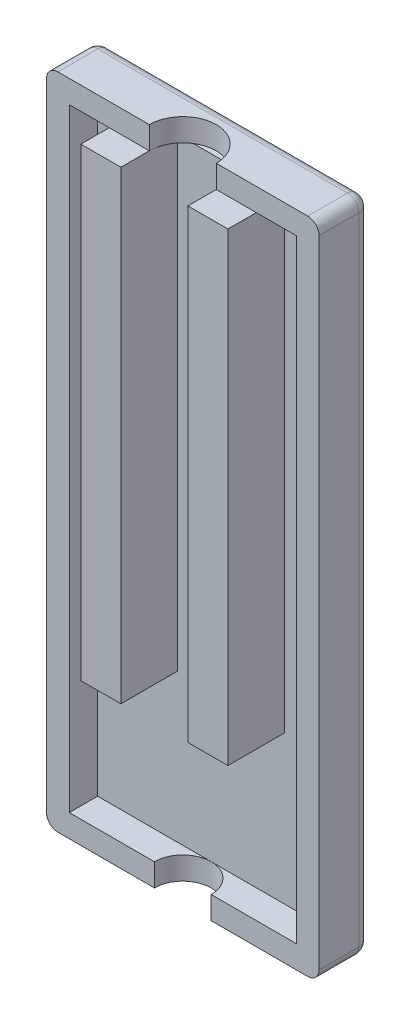
from build123d import *

# Parameters (mm, degrees)
SKETCH1_W           = 24
SKETCH1_H           = 58
BOSS_EXTRUDE1_DEPTH = 2
BOSS_EXTRUDE2_DEPTH = 2.5
CUT_EXTRUDE3_DEPTH  = 3
CUT_EXTRUDE4_DEPTH  = 3
SKETCH7_W           = 3.525
SKETCH7_H           = 40.926519782
BOSS_EXTRUDE3_DEPTH = 5
FILLET1_R           = 1


with BuildPart() as part:
    # Sketch1 → Boss-Extrude1 (new body)
    with BuildSketch(Plane.XY):
        with Locations((0, 4)):
            Rectangle(SKETCH1_W, SKETCH1_H)
    extrude(amount=BOSS_EXTRUDE1_DEPTH)

    # Sketch2 → Boss-Extrude2 (add)
    with BuildSketch(Plane.XY.offset(2)):
        Polygon((12, 33), (-12, 33), (-12, -25), (12, -25), (12, 9), align=None)
        Polygon((-10, -23), (-10, 23), (-10, 31), (10, 31), (10, 23), (10, -23), align=None, mode=Mode.SUBTRACT)
    extrude(amount=BOSS_EXTRUDE2_DEPTH)

    # Sketch5 → Cut-Extrude3 (cut, through all)
    with BuildSketch(Plane.XZ.offset(-31)):
        with BuildLine():
            Line((-2.95, 4.5), (2.95, 4.5))
            ThreePointArc((2.95, 4.5), (0, 1.55), (-2.95, 4.5))
        make_face()
    extrude(amount=-CUT_EXTRUDE3_DEPTH, mode=Mode.SUBTRACT)

    # Sketch6 → Cut-Extrude4 (cut, through all)
    with BuildSketch(Plane(origin=(0, -23, 0), x_dir=(1, 0, 0), z_dir=(0, 1, 0))):
        with BuildLine():
            Line((-2.5, -4.5), (2.5, -4.5))
            ThreePointArc((2.5, -4.5), (0, -2), (-2.5, -4.5))
        make_face()
    extrude(amount=-CUT_EXTRUDE4_DEPTH, mode=Mode.SUBTRACT)

    # Sketch7 → Boss-Extrude3 (add)
    with BuildSketch(Plane.XY.offset(2)):
        with Locations((-4.7125, 10.536740109)):
            Rectangle(SKETCH7_W, SKETCH7_H)
        with Locations((4.7125, 10.536740109)):
            Rectangle(SKETCH7_W, SKETCH7_H)
    extrude(amount=BOSS_EXTRUDE3_DEPTH)

    # Fillet1
    fillet1_edges = [part.edges().sort_by_distance(p)[0] for p in [
        (0, -25, 0),
        (-12, 4, 0),
        (0, 33, 0),
        (12, 4, 0),
        (12, -25, 2.25),
        (-12, -25, 2.25),
        (-12, 33, 2.25),
        (12, 33, 2.25),
    ]]
    fillet(fillet1_edges, radius=FILLET1_R)


solid = part.part
